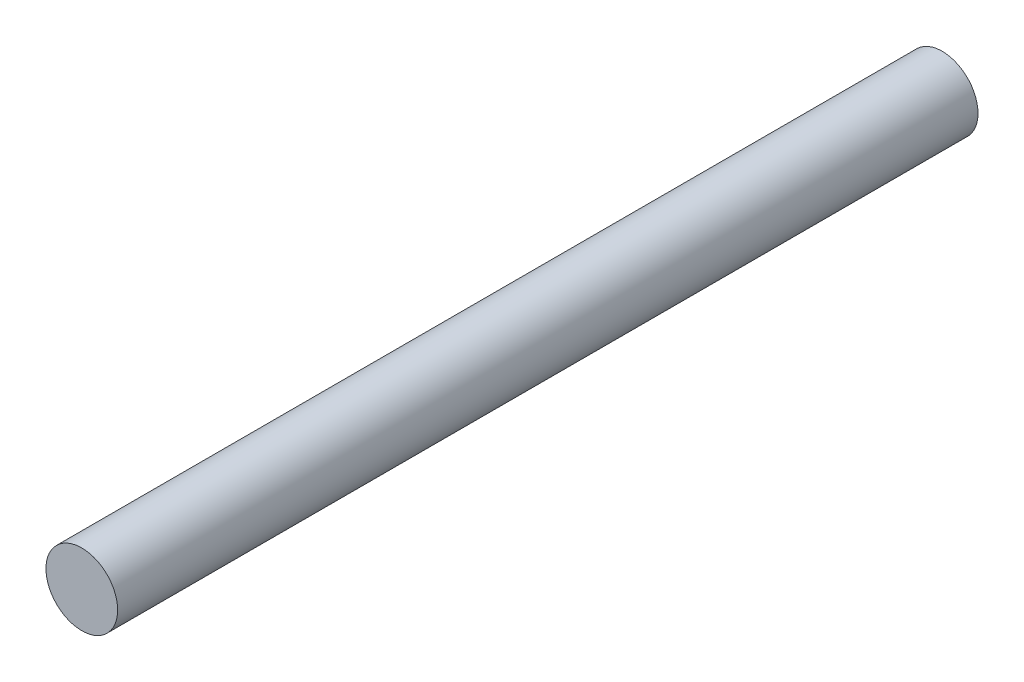
from build123d import *

# Parameters (mm, degrees)
SKETCH1_R           = 2.5
BOSS_EXTRUDE1_DEPTH = 60


with BuildPart() as part:
    # Sketch1 → Boss-Extrude1 (new body)
    with BuildSketch(Plane.XY):
        Circle(SKETCH1_R)
    extrude(amount=BOSS_EXTRUDE1_DEPTH)


solid = part.part
